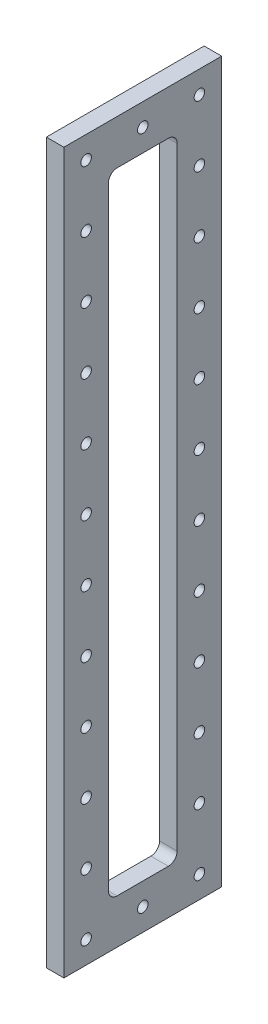
from build123d import *

# Parameters (mm, degrees)
SKETCH1_W           = 90
SKETCH1_H           = 410.4
SKETCH1_R           = 3
BOSS_EXTRUDE1_DEPTH = 10


with BuildPart() as part:
    # Sketch1 → Boss-Extrude1 (new body)
    with BuildSketch(Plane(origin=(2615, 0, 0), x_dir=(0, 0, -1), z_dir=(1, 0, 0))):
        with Locations((-925, 999.8)):
            Rectangle(SKETCH1_W, SKETCH1_H)
        with Locations((-957.3, 807.3)):
            Circle(SKETCH1_R, mode=Mode.SUBTRACT)
        with Locations((-892.7, 807.3)):
            Circle(SKETCH1_R, mode=Mode.SUBTRACT)
        with Locations((-957.3, 842.3)):
            Circle(SKETCH1_R, mode=Mode.SUBTRACT)
        with Locations((-892.7, 842.3)):
            Circle(SKETCH1_R, mode=Mode.SUBTRACT)
        with Locations((-957.3, 877.3)):
            Circle(SKETCH1_R, mode=Mode.SUBTRACT)
        with Locations((-892.7, 877.3)):
            Circle(SKETCH1_R, mode=Mode.SUBTRACT)
        with Locations((-957.3, 912.3)):
            Circle(SKETCH1_R, mode=Mode.SUBTRACT)
        with Locations((-892.7, 912.3)):
            Circle(SKETCH1_R, mode=Mode.SUBTRACT)
        with Locations((-957.3, 947.3)):
            Circle(SKETCH1_R, mode=Mode.SUBTRACT)
        with Locations((-892.7, 947.3)):
            Circle(SKETCH1_R, mode=Mode.SUBTRACT)
        with Locations((-957.3, 982.3)):
            Circle(SKETCH1_R, mode=Mode.SUBTRACT)
        with Locations((-892.7, 982.3)):
            Circle(SKETCH1_R, mode=Mode.SUBTRACT)
        with Locations((-957.3, 1017.3)):
            Circle(SKETCH1_R, mode=Mode.SUBTRACT)
        with Locations((-892.7, 1017.3)):
            Circle(SKETCH1_R, mode=Mode.SUBTRACT)
        with Locations((-957.3, 1052.3)):
            Circle(SKETCH1_R, mode=Mode.SUBTRACT)
        with Locations((-892.7, 1052.3)):
            Circle(SKETCH1_R, mode=Mode.SUBTRACT)
        with Locations((-957.3, 1087.3)):
            Circle(SKETCH1_R, mode=Mode.SUBTRACT)
        with Locations((-892.7, 1087.3)):
            Circle(SKETCH1_R, mode=Mode.SUBTRACT)
        with Locations((-957.3, 1122.3)):
            Circle(SKETCH1_R, mode=Mode.SUBTRACT)
        with Locations((-892.7, 1122.3)):
            Circle(SKETCH1_R, mode=Mode.SUBTRACT)
        with Locations((-957.3, 1157.3)):
            Circle(SKETCH1_R, mode=Mode.SUBTRACT)
        with Locations((-892.7, 1157.3)):
            Circle(SKETCH1_R, mode=Mode.SUBTRACT)
        with Locations((-957.3, 1192.3)):
            Circle(SKETCH1_R, mode=Mode.SUBTRACT)
        with Locations((-892.7, 1192.3)):
            Circle(SKETCH1_R, mode=Mode.SUBTRACT)
        with Locations((-925, 807.3)):
            Circle(SKETCH1_R, mode=Mode.SUBTRACT)
        with Locations((-925, 1192.3)):
            Circle(SKETCH1_R, mode=Mode.SUBTRACT)
        with BuildLine():
            Line((-939.6, 1179.6), (-910.4, 1179.6))
            ThreePointArc((-910.4, 1179.6), (-906.864466094, 1178.135533906), (-905.4, 1174.6))
            Line((-905.4, 1174.6), (-905.4, 825))
            ThreePointArc((-905.4, 825), (-906.864466094, 821.464466094), (-910.4, 820))
            Line((-910.4, 820), (-939.6, 820))
            ThreePointArc((-939.6, 820), (-943.135533906, 821.464466094), (-944.6, 825))
            Line((-944.6, 825), (-944.6, 1174.6))
            ThreePointArc((-944.6, 1174.6), (-943.135533906, 1178.135533906), (-939.6, 1179.6))
        make_face(mode=Mode.SUBTRACT)
    extrude(amount=BOSS_EXTRUDE1_DEPTH)


solid = part.part
